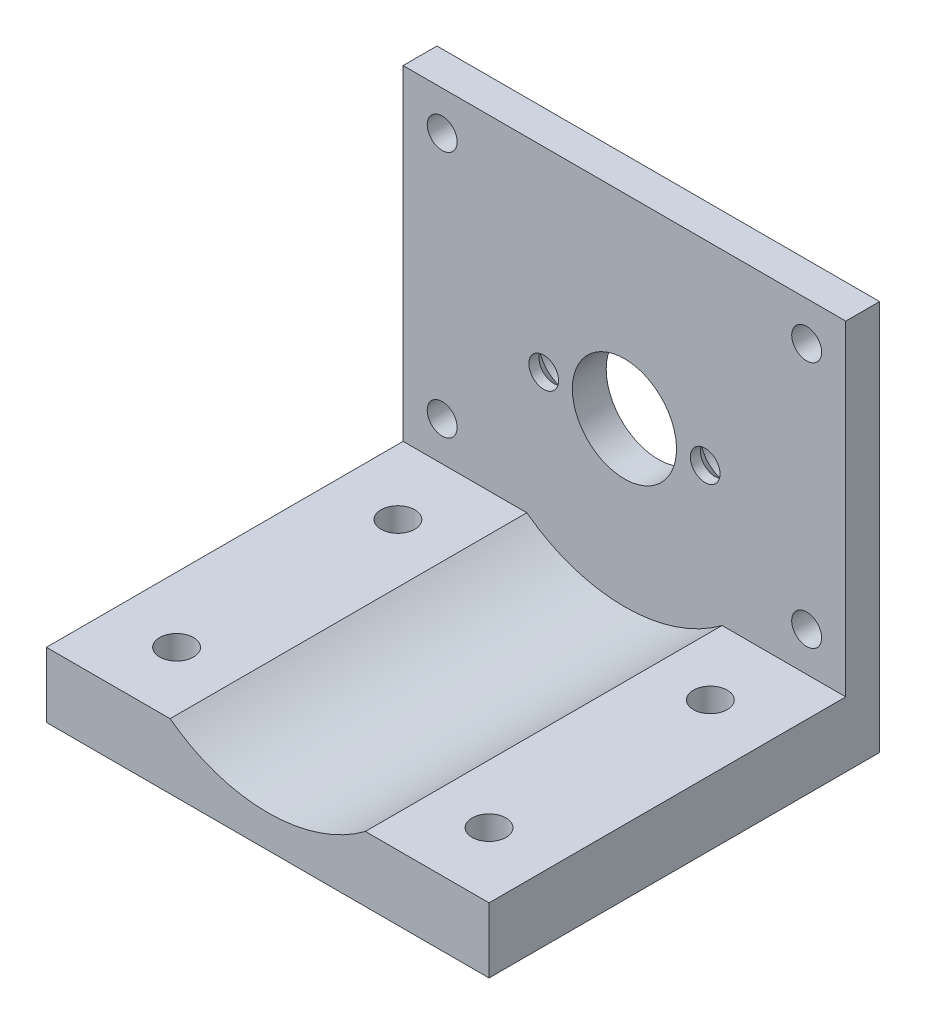
from build123d import *

# Parameters (mm, degrees)
SKETCH2_W                                      = 43.18
SKETCH2_H                                      = 38.1
BOSS_EXTRUDE1_DEPTH                            = 3.302
SKETCH4_R                                      = 5.08
SKETCH4_R_2                                    = 1.4605
CUT_EXTRUDE1_DEPTH                             = 4.302
CSK_FOR_M2_5_OVAL_HEAD_MACHINE_SCREW1_AT_COUNT = 2
CSK_FOR_M2_5_OVAL_HEAD_MACHINE_SCREW1_AT_PITCH = 15.748
BOSS_EXTRUDE2_START                            = -3.302
BOSS_EXTRUDE2_DEPTH                            = 38.1
SKETCH9_R                                      = 1.651
CUT_EXTRUDE2_DEPTH                             = 7.35
SKETCH10_W                                     = 0.569871795
SKETCH10_H                                     = 2.320192308
CUT_EXTRUDE3_DEPTH                             = 1.27


with BuildPart() as part:
    # Sketch2 → Boss-Extrude1 (new body)
    with BuildSketch(Plane.XY):
        with Locations((21.59, 19.05)):
            Rectangle(SKETCH2_W, SKETCH2_H)
    extrude(amount=BOSS_EXTRUDE1_DEPTH)

    # Sketch4 → Cut-Extrude1 (cut, through all)
    with BuildSketch(Plane(origin=(0, 0, 0), x_dir=(-1, 0, 0), z_dir=(0, 0, -1))):
        with Locations((-21.59, 19.05)):
            Circle(SKETCH4_R)
        with Locations((-3.81, 34.29)):
            Circle(SKETCH4_R_2)
        with Locations((-3.81, 10.16)):
            Circle(SKETCH4_R_2)
        with Locations((-39.37, 10.16)):
            Circle(SKETCH4_R_2)
        with Locations((-39.37, 34.29)):
            Circle(SKETCH4_R_2)
    extrude(amount=-CUT_EXTRUDE1_DEPTH, mode=Mode.SUBTRACT)

    # Sketch7 → CSK for M2.5 Oval Head Machine Screw1 (revolve, cut)
    with BuildSketch(Plane(origin=(29.464, 19.05, 0), x_dir=(0, 1, 0), z_dir=(1, 0, 0))):
        Polygon((0, 0), (0, 3.302), (1.45, 3.302), (1.45, 2.316), (2.75, 1.016), (2.75, 0), align=None)
    csk_for_m2_5_oval_head_machine_screw1 = revolve(axis=Axis((29.464, 19.05, -6.35), (0, 0, 1)), mode=Mode.SUBTRACT)

    # CSK for M2.5 Oval Head Machine Screw1 at: CSK for M2.5 Oval Head Machine Screw1 ×2
    with Locations(*[(-i * CSK_FOR_M2_5_OVAL_HEAD_MACHINE_SCREW1_AT_PITCH, 0, 0) for i in range(1, CSK_FOR_M2_5_OVAL_HEAD_MACHINE_SCREW1_AT_COUNT)]):
        add(csk_for_m2_5_oval_head_machine_screw1, mode=Mode.SUBTRACT)

    # Sketch8 → Boss-Extrude2 (add)
    with BuildSketch(Plane.XY.offset(3.302).offset(BOSS_EXTRUDE2_START)):
        with BuildLine():
            Line((31.115, 6.35), (43.18, 6.35))
            Line((43.18, 6.35), (43.18, 0))
            Line((43.18, 0), (0, 0))
            Line((0, 0), (0, 6.35))
            Line((0, 6.35), (12.065, 6.35))
            ThreePointArc((12.065, 6.35), (21.59, 3.175), (31.115, 6.35))
        make_face()
    extrude(amount=BOSS_EXTRUDE2_DEPTH)

    # Sketch9 → Cut-Extrude2 (cut, through all)
    with BuildSketch(Plane(origin=(0, 6.35, 0), x_dir=(1, 0, 0), z_dir=(0, 1, 0))):
        with Locations((6.35, -31.75)):
            Circle(SKETCH9_R)
        with Locations((6.35, -10.16)):
            Circle(SKETCH9_R)
        with Locations((36.83, -10.16)):
            Circle(SKETCH9_R)
        with Locations((36.83, -31.75)):
            Circle(SKETCH9_R)
    extrude(amount=-CUT_EXTRUDE2_DEPTH, mode=Mode.SUBTRACT)

    # Sketch10 → Cut-Extrude3 (cut)
    with BuildSketch(Plane(origin=(0, 0, 0), x_dir=(-1, 0, 0), z_dir=(0, 0, -1))):
        with BuildLine():
            Line((-35.883720469, 29.845), (-35.313848674, 29.845))
            Line((-35.313848674, 29.845), (-35.313848674, 27.73723758))
            add(Edge.make_bspline(
                [(-35.313848674, 27.73723758), (-35.314057606, 27.69695254), (-35.314460177, 27.619331222), (-35.318490626, 27.507585177), (-35.323940504, 27.405130731), (-35.331788854, 27.312132049), (-35.343445802, 27.228593628), (-35.356637927, 27.154307047), (-35.371192504, 27.08896961), (-35.395778755, 27.015846852), (-35.433948198, 26.934871717), (-35.491546976, 26.847407063), (-35.563275891, 26.771415182), (-35.645883908, 26.705407451), (-35.740067061, 26.653141814), (-35.843655591, 26.615364071), (-35.95631835, 26.592795386), (-36.034351478, 26.590019084), (-36.074525758, 26.588589744)],
                knots=[0, 0, 0, 0, 0.00012085, 0.000232854, 0.000335413, 0.000428639, 0.00051274, 0.000588343, 0.000654989, 0.000713315, 0.000819441, 0.000922634, 0.001026135, 0.001131624, 0.001238681, 0.001347739, 0.001461247, 0.001581696, 0.001581696, 0.001581696, 0.001581696], degree=3))
            add(Edge.make_bspline(
                [(-36.074525758, 26.588589744), (-36.116383701, 26.589885617), (-36.198943911, 26.592441587), (-36.320026962, 26.61421188), (-36.436402909, 26.64911621), (-36.547469686, 26.699583683), (-36.654748941, 26.762801011), (-36.756293653, 26.841215953), (-36.854223938, 26.932396519), (-36.912277608, 27.002366196), (-36.942053803, 27.038254207)],
                knots=[0, 0, 0, 0, 0.000125491, 0.000247517, 0.000367833, 0.000489111, 0.000612587, 0.000740558, 0.00087329, 0.001013058, 0.001013058, 0.001013058, 0.001013058], degree=3))
            Line((-36.942053803, 27.038254207), (-36.510833851, 27.43703726))
            add(Edge.make_bspline(
                [(-36.510833851, 27.43703726), (-36.488255661, 27.411507703), (-36.446005797, 27.363735039), (-36.382336499, 27.301438312), (-36.324903361, 27.251390082), (-36.270762922, 27.215289844), (-36.219671889, 27.189843205), (-36.170531002, 27.171513276), (-36.121808469, 27.161137495), (-36.089620879, 27.159340023), (-36.07388974, 27.158461538)],
                knots=[0, 0, 0, 0, 0.000102209, 0.000191261, 0.000267078, 0.000330405, 0.00038587, 0.000437981, 0.000487378, 0.000534598, 0.000534598, 0.000534598, 0.000534598], degree=3))
            add(Edge.make_bspline(
                [(-36.07388974, 27.158461538), (-36.058663749, 27.159255549), (-36.029389174, 27.160782171), (-35.98913551, 27.177752509), (-35.955199081, 27.204396654), (-35.932857339, 27.235027555), (-35.918619737, 27.266340582), (-35.909723815, 27.296609437), (-35.901281569, 27.33289359), (-35.89451783, 27.375174856), (-35.889407137, 27.424004736), (-35.886859826, 27.478790439), (-35.883761969, 27.539828017), (-35.883734794, 27.582468063), (-35.883720469, 27.604945913)],
                knots=[0, 0, 0, 0, 4.5443e-05, 8.7372e-05, 0.000128596, 0.000173627, 0.000199525, 0.00023151, 0.000268074, 0.000311257, 0.000359862, 0.000415287, 0.000475762, 0.000543183, 0.000543183, 0.000543183, 0.000543183], degree=3))
            Line((-35.883720469, 27.604945913), (-35.883720469, 29.845))
        make_face()
        with BuildLine():
            Line((-32.91224611, 28.990192308), (-32.342374315, 28.990192308))
            Line((-32.342374315, 28.990192308), (-32.342374315, 26.67))
            Line((-32.342374315, 26.67), (-32.91224611, 26.67))
            Line((-32.91224611, 26.67), (-32.91224611, 26.923135016))
            add(Edge.make_bspline(
                [(-32.91224611, 26.923135016), (-32.940483048, 26.898495124), (-32.995285367, 26.850673959), (-33.08163609, 26.788624782), (-33.168239139, 26.73744223), (-33.255510645, 26.696678118), (-33.344791934, 26.666578018), (-33.436725796, 26.644784842), (-33.532636176, 26.631932873), (-33.597834731, 26.630183365), (-33.63094603, 26.629294872)],
                knots=[0, 0, 0, 0, 0.000112381, 0.000218109, 0.000318463, 0.000413791, 0.000506513, 0.000600617, 0.000696864, 0.000796183, 0.000796183, 0.000796183, 0.000796183], degree=3))
            add(Edge.make_bspline(
                [(-33.63094603, 26.629294872), (-33.668114935, 26.630131056), (-33.741562798, 26.631783403), (-33.849339383, 26.649177023), (-33.95340839, 26.675801836), (-34.053685345, 26.713479273), (-34.149987803, 26.762301846), (-34.243052769, 26.820995704), (-34.331284827, 26.891621354), (-34.415418478, 26.971123004), (-34.492450744, 27.058575384), (-34.559793079, 27.152764668), (-34.616557662, 27.252354988), (-34.663061847, 27.357016157), (-34.699643394, 27.466671359), (-34.725720803, 27.581668388), (-34.741106504, 27.702048314), (-34.74301082, 27.784046405), (-34.743976879, 27.82564403)],
                knots=[0, 0, 0, 0, 0.000111419, 0.000220171, 0.000326612, 0.000433285, 0.000540802, 0.000650021, 0.000762762, 0.000879285, 0.000996914, 0.00111181, 0.00122604, 0.001340213, 0.001454856, 0.001572271, 0.001693444, 0.001818207, 0.001818207, 0.001818207, 0.001818207], degree=3))
            add(Edge.make_bspline(
                [(-34.743976879, 27.82564403), (-34.742962996, 27.868718426), (-34.740974152, 27.953213653), (-34.726425873, 28.077206381), (-34.70082969, 28.195054751), (-34.665927456, 28.306922001), (-34.621031792, 28.412827458), (-34.566351873, 28.512944627), (-34.50114383, 28.607011819), (-34.42600312, 28.693427944), (-34.344869608, 28.772632497), (-34.258071094, 28.841586342), (-34.166964917, 28.900165841), (-34.071454259, 28.947989445), (-33.971552761, 28.984945106), (-33.867654831, 29.011962712), (-33.759299237, 29.028174224), (-33.685486529, 29.02998216), (-33.648118506, 29.030897436)],
                knots=[0, 0, 0, 0, 0.000129212, 0.000253463, 0.000373846, 0.000490516, 0.000604512, 0.000718367, 0.000832164, 0.000947164, 0.00106141, 0.001171865, 0.001279133, 0.001385797, 0.001491651, 0.001598092, 0.001707378, 0.001819433, 0.001819433, 0.001819433, 0.001819433], degree=3))
            add(Edge.make_bspline(
                [(-33.648118506, 29.030897436), (-33.613503609, 29.030178304), (-33.545013205, 29.028755402), (-33.444342179, 29.013305404), (-33.346705804, 28.989938379), (-33.25263669, 28.956644575), (-33.161363253, 28.914604374), (-33.074455451, 28.861924869), (-32.9900121, 28.800820156), (-32.938488378, 28.75309608), (-32.91224611, 28.728789063)],
                knots=[0, 0, 0, 0, 0.000103766, 0.000205316, 0.000304814, 0.000404586, 0.000504179, 0.000605729, 0.000709024, 0.000816246, 0.000816246, 0.000816246, 0.000816246], degree=3))
            Line((-32.91224611, 28.728789063), (-32.91224611, 28.990192308))
        make_face()
        with BuildLine():
            add(Edge.make_bspline(
                [(-33.528547192, 28.501730769), (-33.551254903, 28.501034018), (-33.595760534, 28.499668432), (-33.661212156, 28.491454334), (-33.723764271, 28.476980729), (-33.782970763, 28.455599085), (-33.839714027, 28.429553127), (-33.893132408, 28.396930993), (-33.943666782, 28.358372324), (-33.991019952, 28.314810625), (-34.034189344, 28.266928353), (-34.07140388, 28.21467842), (-34.103030223, 28.159468665), (-34.129777889, 28.10113309), (-34.14892315, 28.038981407), (-34.164086188, 27.973822718), (-34.171954824, 27.905124712), (-34.173381159, 27.858309147), (-34.174105085, 27.834548277)],
                knots=[0, 0, 0, 0, 6.8128e-05, 0.000133527, 0.00019755, 0.000260313, 0.000322059, 0.000384561, 0.000447655, 0.000512472, 0.000577334, 0.000640697, 0.000704517, 0.000767998, 0.000832766, 0.000899269, 0.000968454, 0.001039759, 0.001039759, 0.001039759, 0.001039759], degree=3))
            add(Edge.make_bspline(
                [(-34.174105085, 27.834548277), (-34.173392217, 27.810571883), (-34.171987521, 27.763326676), (-34.16395896, 27.694049178), (-34.14934155, 27.627938674), (-34.128015301, 27.565529623), (-34.101971003, 27.505979922), (-34.070269236, 27.449564396), (-34.031329167, 27.397280544), (-33.988121932, 27.347891154), (-33.939797319, 27.303788346), (-33.888977001, 27.264629101), (-33.834966812, 27.231864586), (-33.778352726, 27.205384097), (-33.719325307, 27.183804725), (-33.657144532, 27.169513023), (-33.592419538, 27.160376608), (-33.5482948, 27.159104303), (-33.526003121, 27.158461538)],
                knots=[0, 0, 0, 0, 7.194e-05, 0.000141758, 0.000208881, 0.000274649, 0.000339292, 0.000403665, 0.000468289, 0.000534523, 0.00060024, 0.000664225, 0.000726727, 0.000789319, 0.000851483, 0.000914887, 0.000980369, 0.001047227, 0.001047227, 0.001047227, 0.001047227], degree=3))
            add(Edge.make_bspline(
                [(-33.526003121, 27.158461538), (-33.502872453, 27.159162196), (-33.457523767, 27.160535864), (-33.391004336, 27.168674999), (-33.327611922, 27.183201674), (-33.26761027, 27.204705733), (-33.210082914, 27.230564732), (-33.155548986, 27.262549405), (-33.104600261, 27.301019592), (-33.056978707, 27.34497509), (-33.013342733, 27.393248349), (-32.97561355, 27.446183457), (-32.942750052, 27.502087404), (-32.916904422, 27.562281961), (-32.896379367, 27.625714007), (-32.881653114, 27.692777213), (-32.873642886, 27.763543882), (-32.872250475, 27.811844891), (-32.871540982, 27.83645633)],
                knots=[0, 0, 0, 0, 6.9399e-05, 0.000136059, 0.000200702, 0.000264065, 0.000326966, 0.000389688, 0.000453289, 0.000518107, 0.000583866, 0.000648117, 0.000712806, 0.000778031, 0.000844205, 0.00091257, 0.000983651, 0.001057497, 0.001057497, 0.001057497, 0.001057497], degree=3))
            add(Edge.make_bspline(
                [(-32.871540982, 27.83645633), (-32.872241659, 27.860644464), (-32.873610285, 27.907890916), (-32.88168766, 27.977180011), (-32.896518462, 28.042926402), (-32.916621077, 28.10525094), (-32.942926508, 28.164011121), (-32.975814872, 28.218555434), (-33.013130188, 28.270773636), (-33.057249275, 28.317742768), (-33.104612852, 28.361379994), (-33.15631086, 28.398686815), (-33.210714533, 28.430838869), (-33.268158126, 28.457236944), (-33.329173542, 28.476587735), (-33.39267429, 28.491570343), (-33.459651113, 28.499663502), (-33.505207064, 28.501030435), (-33.528547192, 28.501730769)],
                knots=[0, 0, 0, 0, 7.2576e-05, 0.000141761, 0.000208885, 0.000274453, 0.000337934, 0.000401526, 0.000465261, 0.000530079, 0.000594468, 0.000658203, 0.000720924, 0.000783826, 0.000847383, 0.000912645, 0.000979306, 0.00104934, 0.00104934, 0.00104934, 0.00104934], degree=3))
        make_face(mode=Mode.SUBTRACT)
        with BuildLine():
            Line((-29.533720469, 28.516995192), (-30.005645549, 28.2575))
            add(Edge.make_bspline(
                [(-30.005645549, 28.2575), (-30.027276875, 28.279161867), (-30.068857721, 28.320801421), (-30.13553595, 28.37351049), (-30.201022726, 28.417152133), (-30.268017799, 28.449357424), (-30.337120025, 28.473611095), (-30.410821836, 28.489674834), (-30.489983464, 28.500252235), (-30.544739652, 28.501227763), (-30.572973274, 28.501730769)],
                knots=[0, 0, 0, 0, 9.1763e-05, 0.000176392, 0.000254542, 0.000327362, 0.000398769, 0.000473757, 0.000553277, 0.000637927, 0.000637927, 0.000637927, 0.000637927], degree=3))
            add(Edge.make_bspline(
                [(-30.572973274, 28.501730769), (-30.598865453, 28.501105378), (-30.649534278, 28.499881538), (-30.72356947, 28.4907403), (-30.793932334, 28.476382899), (-30.860496565, 28.455377972), (-30.923143604, 28.42762932), (-30.982391515, 28.394792964), (-31.037664566, 28.355586361), (-31.088181455, 28.310566822), (-31.133781827, 28.261001308), (-31.174459686, 28.208137557), (-31.207784458, 28.151191348), (-31.23659579, 28.091501123), (-31.257778233, 28.027945767), (-31.273275824, 27.961101977), (-31.282109306, 27.890966794), (-31.283389122, 27.843052482), (-31.284040982, 27.818647837)],
                knots=[0, 0, 0, 0, 7.7659e-05, 0.000151973, 0.000223448, 0.000292844, 0.000360909, 0.000428677, 0.000495737, 0.000563767, 0.000631281, 0.000697555, 0.000763438, 0.000828873, 0.000896051, 0.000963935, 0.001034461, 0.001107672, 0.001107672, 0.001107672, 0.001107672], degree=3))
            add(Edge.make_bspline(
                [(-31.284040982, 27.818647837), (-31.283352235, 27.794880072), (-31.282007409, 27.748471829), (-31.273745246, 27.68028706), (-31.259401822, 27.61537807), (-31.237895734, 27.554088013), (-31.212118283, 27.495851883), (-31.179746524, 27.441132841), (-31.141679119, 27.389691945), (-31.097715658, 27.341976291), (-31.0490153, 27.299061914), (-30.996512496, 27.261164076), (-30.940363891, 27.229033721), (-30.879915412, 27.203818613), (-30.816152609, 27.183273576), (-30.748649673, 27.168644704), (-30.677478437, 27.160524669), (-30.628962808, 27.159159879), (-30.604138137, 27.158461538)],
                knots=[0, 0, 0, 0, 7.1305e-05, 0.000139228, 0.000205731, 0.000270295, 0.000333776, 0.000396497, 0.000460609, 0.000525426, 0.000590763, 0.000655013, 0.000719386, 0.00078436, 0.000851139, 0.000920125, 0.000991206, 0.001065688, 0.001065688, 0.001065688, 0.001065688], degree=3))
            add(Edge.make_bspline(
                [(-30.604138137, 27.158461538), (-30.573573018, 27.159160958), (-30.513914347, 27.160526123), (-30.427187952, 27.172105012), (-30.345579602, 27.191252424), (-30.26908064, 27.217753962), (-30.197798092, 27.252405217), (-30.131915113, 27.29472914), (-30.070754426, 27.344413514), (-30.035088883, 27.38314857), (-30.017093867, 27.402692308)],
                knots=[0, 0, 0, 0, 9.1666e-05, 0.000178919, 0.000261916, 0.000342778, 0.000421287, 0.000499092, 0.00057727, 0.000656884, 0.000656884, 0.000656884, 0.000656884], degree=3))
            Line((-30.017093867, 27.402692308), (-29.574425597, 27.098675881))
            add(Edge.make_bspline(
                [(-29.574425597, 27.098675881), (-29.605109236, 27.061161254), (-29.665661062, 26.987128988), (-29.771307209, 26.891704101), (-29.885014373, 26.809712919), (-30.00906945, 26.744268597), (-30.141665788, 26.692216005), (-30.283839501, 26.65541999), (-30.435350111, 26.633759744), (-30.539404933, 26.630806952), (-30.59268982, 26.629294872)],
                knots=[0, 0, 0, 0, 0.000145216, 0.000286572, 0.000425645, 0.000564783, 0.000706159, 0.000852094, 0.001004374, 0.001164196, 0.001164196, 0.001164196, 0.001164196], degree=3))
            add(Edge.make_bspline(
                [(-30.59268982, 26.629294872), (-30.640649523, 26.630403558), (-30.734320112, 26.632568944), (-30.870842668, 26.649151716), (-30.999249221, 26.677083137), (-31.119803923, 26.715874142), (-31.232396863, 26.766123017), (-31.336662892, 26.828450398), (-31.433305283, 26.901122564), (-31.520580219, 26.984482815), (-31.598449487, 27.075221348), (-31.666429639, 27.17078345), (-31.725221983, 27.269456927), (-31.771344521, 27.372884161), (-31.809039345, 27.479453062), (-31.834497246, 27.59043751), (-31.8512883, 27.704923312), (-31.85303091, 27.782546076), (-31.853912777, 27.821827925)],
                knots=[0, 0, 0, 0, 0.000143854, 0.000280963, 0.000411829, 0.000537537, 0.000660236, 0.000780875, 0.00090121, 0.001022229, 0.001142196, 0.001259383, 0.0013737, 0.001486133, 0.001598572, 0.00171227, 0.001827222, 0.001944995, 0.001944995, 0.001944995, 0.001944995], degree=3))
            add(Edge.make_bspline(
                [(-31.853912777, 27.821827925), (-31.853440354, 27.849195922), (-31.852504631, 27.903403508), (-31.844516511, 27.98390782), (-31.832089681, 28.063046005), (-31.813413622, 28.140262556), (-31.790445366, 28.215932099), (-31.762524341, 28.290039423), (-31.728549239, 28.362202122), (-31.690649909, 28.433034055), (-31.647455228, 28.500665364), (-31.600330727, 28.5650662), (-31.549342801, 28.625842136), (-31.493892469, 28.682426759), (-31.434366367, 28.735224953), (-31.371629851, 28.785307896), (-31.303652796, 28.830092695), (-31.232798349, 28.872198679), (-31.15845617, 28.909681114), (-31.081480722, 28.942033398), (-31.002466853, 28.969521328), (-30.921225171, 28.991622179), (-30.838104381, 29.009837332), (-30.752364856, 29.021397417), (-30.664715945, 29.029522752), (-30.605429468, 29.030436445), (-30.575517344, 29.030897436)],
                knots=[0, 0, 0, 0, 8.2086e-05, 0.000162587, 0.000242472, 0.000322228, 0.000400693, 0.0004796, 0.000559559, 0.000639811, 0.000720445, 0.000800079, 0.000879071, 0.000958229, 0.00103751, 0.001117671, 0.001198815, 0.001281497, 0.001364837, 0.001448352, 0.001531825, 0.001615611, 0.001700811, 0.00178689, 0.001874991, 0.001964706, 0.001964706, 0.001964706, 0.001964706], degree=3))
            add(Edge.make_bspline(
                [(-30.575517344, 29.030897436), (-30.547732819, 29.030583308), (-30.49293586, 29.029963782), (-30.412013137, 29.023485774), (-30.333297823, 29.012482593), (-30.256655957, 28.997925848), (-30.181854779, 28.979887505), (-30.109896824, 28.955842999), (-30.039798304, 28.92855339), (-29.949510671, 28.88734893), (-29.843078076, 28.825844605), (-29.726243603, 28.737633843), (-29.622071525, 28.634440118), (-29.563327353, 28.556351578), (-29.533720469, 28.516995192)],
                knots=[0, 0, 0, 0, 8.334e-05, 0.000164364, 0.000243338, 0.000321674, 0.00039834, 0.000473965, 0.000549082, 0.000623933, 0.000771534, 0.000916802, 0.001062067, 0.001209672, 0.001209672, 0.001209672, 0.001209672], degree=3))
        make_face()
        Polygon((-28.963848674, 29.926410256), (-28.393976879, 29.926410256), (-28.393976879, 28.027261619), (-27.507368306, 28.990192308), (-26.803296791, 28.990192308), (-27.821561014, 27.884157652), (-26.657648754, 26.67), (-27.375076639, 26.67), (-28.393976879, 27.732785457), (-28.393976879, 26.67), (-28.963848674, 26.67), align=None)
        with BuildLine():
            Line((-22.187080846, 29.340002003), (-22.618300798, 28.927226563))
            add(Edge.make_bspline(
                [(-22.618300798, 28.927226563), (-22.652441234, 28.961407905), (-22.719430406, 29.028477342), (-22.828982816, 29.115772823), (-22.942445866, 29.189991239), (-23.060193006, 29.251018813), (-23.182388259, 29.298357105), (-23.308790483, 29.3322197), (-23.439605317, 29.352304178), (-23.52816112, 29.355115937), (-23.572963258, 29.356538462)],
                knots=[0, 0, 0, 0, 0.000144839, 0.000284198, 0.000419327, 0.000551032, 0.00068131, 0.000811675, 0.000942912, 0.001077294, 0.001077294, 0.001077294, 0.001077294], degree=3))
            add(Edge.make_bspline(
                [(-23.572963258, 29.356538462), (-23.611805341, 29.355541705), (-23.688075177, 29.353584486), (-23.800146355, 29.338721502), (-23.907237231, 29.313893554), (-24.009853746, 29.279498578), (-24.107369391, 29.234739844), (-24.200349189, 29.18030815), (-24.288220942, 29.115787088), (-24.370292724, 29.042399755), (-24.445019345, 28.962275604), (-24.510259631, 28.87651443), (-24.565830339, 28.786714749), (-24.611576365, 28.692417132), (-24.646384116, 28.593766307), (-24.671232296, 28.49083389), (-24.687004711, 28.383919017), (-24.688866962, 28.310980583), (-24.689810213, 28.274036458)],
                knots=[0, 0, 0, 0, 0.000116502, 0.000228763, 0.000338455, 0.000445857, 0.000552869, 0.000659769, 0.000768536, 0.000879349, 0.000989608, 0.001096716, 0.001202091, 0.00130592, 0.001410525, 0.001515267, 0.001623203, 0.001733987, 0.001733987, 0.001733987, 0.001733987], degree=3))
            add(Edge.make_bspline(
                [(-24.689810213, 28.274036458), (-24.688930394, 28.235813648), (-24.687197029, 28.160509478), (-24.670546105, 28.049997372), (-24.644892491, 27.943676762), (-24.607342439, 27.842336523), (-24.561129697, 27.744588436), (-24.502524326, 27.652325972), (-24.434184599, 27.564140184), (-24.356232629, 27.481566437), (-24.271441017, 27.405453315), (-24.179608942, 27.339796177), (-24.083530499, 27.283148239), (-23.981654978, 27.238284903), (-23.875750636, 27.202264559), (-23.764743299, 27.176867125), (-23.648882928, 27.161285888), (-23.569832442, 27.15941236), (-23.529714059, 27.158461538)],
                knots=[0, 0, 0, 0, 0.000114596, 0.00022577, 0.000334522, 0.000442167, 0.000549413, 0.000658292, 0.000769355, 0.000883644, 0.000998524, 0.001110611, 0.001221769, 0.00133252, 0.001443945, 0.001556879, 0.001673636, 0.001793951, 0.001793951, 0.001793951, 0.001793951], degree=3))
            add(Edge.make_bspline(
                [(-23.529714059, 27.158461538), (-23.503618536, 27.158696994), (-23.452387219, 27.159159245), (-23.377239607, 27.166662884), (-23.305266244, 27.177390208), (-23.236188398, 27.191591911), (-23.170703569, 27.211689869), (-23.107905075, 27.235191957), (-23.04816086, 27.262929106), (-22.991794851, 27.2958583), (-22.937968158, 27.332767902), (-22.887184609, 27.375000335), (-22.838553402, 27.421603414), (-22.792642785, 27.473146461), (-22.750229809, 27.530090332), (-22.70995567, 27.591388607), (-22.672281501, 27.657649634), (-22.650020828, 27.704439815), (-22.638653362, 27.728333333)],
                knots=[0, 0, 0, 0, 7.8253e-05, 0.000153629, 0.000226308, 0.000296538, 0.000364951, 0.000431575, 0.000497586, 0.000562275, 0.000627199, 0.000693161, 0.000760185, 0.000829113, 0.000899965, 0.000972997, 0.001049045, 0.001128405, 0.001128405, 0.001128405, 0.001128405], degree=3))
            Line((-22.638653362, 27.728333333), (-23.550066623, 27.728333333))
            Line((-23.550066623, 27.728333333), (-23.550066623, 28.298205128))
            Line((-23.550066623, 28.298205128), (-21.967018746, 28.298205128))
            Line((-21.967018746, 28.298205128), (-21.962566623, 28.162733373))
            add(Edge.make_bspline(
                [(-21.962566623, 28.162733373), (-21.963138688, 28.127940789), (-21.964281796, 28.058417712), (-21.97472861, 27.954909693), (-21.992033597, 27.852774494), (-22.01569117, 27.752114696), (-22.045340095, 27.652436526), (-22.083151754, 27.554694487), (-22.127428977, 27.458225725), (-22.177038463, 27.363440156), (-22.232785252, 27.272490826), (-22.292804855, 27.186373816), (-22.356241654, 27.105238176), (-22.42447537, 27.03021433), (-22.496443495, 26.960672044), (-22.572287696, 26.896878855), (-22.652276233, 26.838780786), (-22.735985372, 26.785887042), (-22.823891919, 26.739528796), (-22.915512563, 26.699203272), (-23.01070897, 26.664955656), (-23.109726915, 26.636880061), (-23.212371555, 26.615217506), (-23.318645088, 26.600363463), (-23.428605882, 26.590269974), (-23.503189963, 26.589156592), (-23.541162376, 26.588589744)],
                knots=[0, 0, 0, 0, 0.000104355, 0.000208524, 0.000311726, 0.000414935, 0.00051856, 0.000623448, 0.000729039, 0.000836864, 0.000944198, 0.001048825, 0.001151634, 0.001252944, 0.001352801, 0.001451662, 0.001550001, 0.001649173, 0.001748467, 0.001847853, 0.001949249, 0.002051727, 0.002156384, 0.00226369, 0.002373501, 0.002487392, 0.002487392, 0.002487392, 0.002487392], degree=3))
            add(Edge.make_bspline(
                [(-23.541162376, 26.588589744), (-23.581676367, 26.589149516), (-23.66198718, 26.590259153), (-23.78073748, 26.600651657), (-23.89604276, 26.617803815), (-24.00793178, 26.641541814), (-24.116664324, 26.671085651), (-24.222053571, 26.708170155), (-24.323883974, 26.752283344), (-24.422460465, 26.802257086), (-24.516523131, 26.858931662), (-24.605861161, 26.921313277), (-24.689986931, 26.989803203), (-24.769762151, 27.063254905), (-24.843322963, 27.143473831), (-24.913410691, 27.227859699), (-24.976629823, 27.319507443), (-25.035698596, 27.415445818), (-25.088175766, 27.515634621), (-25.134067806, 27.618220808), (-25.173204511, 27.722610404), (-25.204064749, 27.829289482), (-25.229120373, 27.937514186), (-25.247048141, 28.047755162), (-25.25717279, 28.159998608), (-25.258841889, 28.235432018), (-25.259682008, 28.273400441)],
                knots=[0, 0, 0, 0, 0.000121521, 0.000240891, 0.000357284, 0.000471047, 0.00058384, 0.000695077, 0.0008059, 0.000916548, 0.001026388, 0.001135078, 0.001243151, 0.001351612, 0.001460073, 0.001569442, 0.001680425, 0.001793759, 0.001907272, 0.002019444, 0.002130732, 0.002241425, 0.002352357, 0.00246382, 0.00257622, 0.002690131, 0.002690131, 0.002690131, 0.002690131], degree=3))
            add(Edge.make_bspline(
                [(-25.259682008, 28.273400441), (-25.258556909, 28.325197483), (-25.256335172, 28.427481286), (-25.235758519, 28.578145976), (-25.203682581, 28.72389903), (-25.157650382, 28.864209626), (-25.0985802, 28.999271043), (-25.027308818, 29.129400345), (-24.942288067, 29.254459214), (-24.876476166, 29.331888023), (-24.843090461, 29.371166867)],
                knots=[0, 0, 0, 0, 0.000155319, 0.000306708, 0.000455304, 0.00060253, 0.000748932, 0.000896948, 0.001047072, 0.001201639, 0.001201639, 0.001201639, 0.001201639], degree=3))
            add(Edge.make_bspline(
                [(-24.843090461, 29.371166867), (-24.822361603, 29.393890869), (-24.781215132, 29.43899767), (-24.715442572, 29.501674489), (-24.648002002, 29.560593018), (-24.577959358, 29.614503925), (-24.505682843, 29.664587348), (-24.430964431, 29.709904431), (-24.354196078, 29.751898096), (-24.274779084, 29.788423986), (-24.193129207, 29.821172494), (-24.108884834, 29.848882336), (-24.022676937, 29.87342667), (-23.933742143, 29.892098613), (-23.842978905, 29.907647182), (-23.749742955, 29.918068647), (-23.654288367, 29.925706839), (-23.589727685, 29.926173929), (-23.557062817, 29.926410256)],
                knots=[0, 0, 0, 0, 9.2249e-05, 0.000183113, 0.000272382, 0.000360798, 0.000448127, 0.000536045, 0.000622844, 0.000710488, 0.000798122, 0.000886618, 0.000976429, 0.001066871, 0.001159094, 0.00125258, 0.001348238, 0.001446204, 0.001446204, 0.001446204, 0.001446204], degree=3))
            add(Edge.make_bspline(
                [(-23.557062817, 29.926410256), (-23.522917425, 29.925883676), (-23.454980632, 29.924835974), (-23.353969872, 29.917586558), (-23.254362725, 29.906402419), (-23.156578943, 29.889625571), (-23.060290366, 29.868936226), (-22.965995404, 29.842428055), (-22.873078902, 29.812309997), (-22.81259061, 29.788297656), (-22.782393346, 29.776310096)],
                knots=[0, 0, 0, 0, 0.00010243, 0.000203799, 0.000303676, 0.000403009, 0.000501314, 0.00059899, 0.000696738, 0.000794184, 0.000794184, 0.000794184, 0.000794184], degree=3))
            add(Edge.make_bspline(
                [(-22.782393346, 29.776310096), (-22.756986083, 29.765231433), (-22.705308414, 29.742697739), (-22.630123775, 29.701471289), (-22.554755438, 29.655767038), (-22.480016668, 29.603913932), (-22.406021345, 29.54600896), (-22.331996879, 29.482966722), (-22.258698938, 29.414052109), (-22.211262712, 29.365005039), (-22.187080846, 29.340002003)],
                knots=[0, 0, 0, 0, 8.3114e-05, 0.000169052, 0.00025697, 0.000347477, 0.000441749, 0.000538743, 0.000639083, 0.000743425, 0.000743425, 0.000743425, 0.000743425], degree=3))
        make_face()
        with BuildLine():
            add(Edge.make_bspline(
                [(-20.368706447, 29.030897436), (-20.341764008, 29.030417977), (-20.288405772, 29.02946843), (-20.208935346, 29.021564324), (-20.130854245, 29.00866845), (-20.053713671, 28.991970543), (-19.978229946, 28.968574278), (-19.904007166, 28.940514075), (-19.830381687, 28.908297682), (-19.759180877, 28.869948905), (-19.689890364, 28.828356158), (-19.624198835, 28.782475947), (-19.56265181, 28.732668643), (-19.50410677, 28.680089069), (-19.451292006, 28.622448081), (-19.400832373, 28.562523064), (-19.35545408, 28.498167113), (-19.313440318, 28.430948435), (-19.276035768, 28.361255742), (-19.243556796, 28.28957384), (-19.215368101, 28.216893784), (-19.193296918, 28.14233028), (-19.175024013, 28.066866546), (-19.163492511, 27.989577832), (-19.155294413, 27.911258087), (-19.154375146, 27.858526789), (-19.153912777, 27.832004207)],
                knots=[0, 0, 0, 0, 8.0814e-05, 0.000160049, 0.000239307, 0.000318157, 0.000396622, 0.000476125, 0.000556137, 0.00063751, 0.000718554, 0.000798482, 0.000877648, 0.000955984, 0.001034284, 0.001111972, 0.001190861, 0.001270279, 0.00134967, 0.001427941, 0.001506254, 0.001583317, 0.00166107, 0.001738971, 0.001817573, 0.001897116, 0.001897116, 0.001897116, 0.001897116], degree=3))
            add(Edge.make_bspline(
                [(-19.153912777, 27.832004207), (-19.154400731, 27.805274416), (-19.155370894, 27.752129534), (-19.163195914, 27.673073095), (-19.17614115, 27.595420928), (-19.192903144, 27.518715572), (-19.216211854, 27.443938544), (-19.243445593, 27.369987602), (-19.276876079, 27.297870725), (-19.313835945, 27.226801186), (-19.356119838, 27.158870345), (-19.40145885, 27.093869703), (-19.451707134, 27.033504533), (-19.504099101, 26.975902744), (-19.56111982, 26.92301217), (-19.621859135, 26.873974009), (-19.685791212, 26.828188747), (-19.753375789, 26.786730594), (-19.823747222, 26.750302794), (-19.895718708, 26.717460159), (-19.969711098, 26.69011632), (-20.04557126, 26.667818172), (-20.123345201, 26.650553275), (-20.202861216, 26.638825025), (-20.283948057, 26.630668162), (-20.338581177, 26.629755582), (-20.366162376, 26.629294872)],
                knots=[0, 0, 0, 0, 8.0179e-05, 0.000159413, 0.000238043, 0.000316273, 0.000394738, 0.000472826, 0.000552519, 0.000633032, 0.000712991, 0.000792399, 0.000870578, 0.000948445, 0.001025846, 0.001103622, 0.001182512, 0.001261596, 0.00134125, 0.001420101, 0.001498785, 0.001577677, 0.001657148, 0.001737564, 0.001818698, 0.001901419, 0.001901419, 0.001901419, 0.001901419], degree=3))
            add(Edge.make_bspline(
                [(-20.366162376, 26.629294872), (-20.406491713, 26.630478617), (-20.485981451, 26.632811798), (-20.603051041, 26.648793474), (-20.715516272, 26.676302129), (-20.823560405, 26.714648588), (-20.92732379, 26.763788146), (-21.025900865, 26.824605811), (-21.120272203, 26.895904257), (-21.208803221, 26.977080864), (-21.289909627, 27.066138954), (-21.36076583, 27.161207921), (-21.420928481, 27.260862843), (-21.470343451, 27.365217359), (-21.508481731, 27.474414568), (-21.536024077, 27.588128009), (-21.552025292, 27.706677312), (-21.55433874, 27.787223129), (-21.555515341, 27.828188101)],
                knots=[0, 0, 0, 0, 0.000120979, 0.000238451, 0.000353683, 0.000467743, 0.000581824, 0.00069745, 0.000814605, 0.000936153, 0.001057272, 0.001175445, 0.001291284, 0.00140594, 0.0015212, 0.001637667, 0.0017564, 0.001879285, 0.001879285, 0.001879285, 0.001879285], degree=3))
            add(Edge.make_bspline(
                [(-21.555515341, 27.828188101), (-21.554297708, 27.871929711), (-21.551904475, 27.95790297), (-21.532901152, 28.083855753), (-21.502554896, 28.204449574), (-21.458994756, 28.319347093), (-21.403350509, 28.428760224), (-21.335421493, 28.532458201), (-21.254872, 28.630464515), (-21.193187218, 28.689742093), (-21.161820429, 28.719884816)],
                knots=[0, 0, 0, 0, 0.000131174, 0.00025782, 0.000381227, 0.000503607, 0.000625633, 0.000748764, 0.000874826, 0.001005248, 0.001005248, 0.001005248, 0.001005248], degree=3))
            add(Edge.make_bspline(
                [(-21.161820429, 28.719884816), (-21.133038265, 28.744869743), (-21.076257012, 28.794159831), (-20.984006165, 28.856676228), (-20.889551708, 28.910671322), (-20.791761562, 28.955065332), (-20.690363115, 28.988537699), (-20.585875976, 29.012902588), (-20.478321871, 29.027868216), (-20.405430606, 29.029882565), (-20.368706447, 29.030897436)],
                knots=[0, 0, 0, 0, 0.000114251, 0.000225395, 0.00033363, 0.000440378, 0.000546975, 0.000653426, 0.000761904, 0.000872053, 0.000872053, 0.000872053, 0.000872053], degree=3))
        make_face()
        with BuildLine():
            add(Edge.make_bspline(
                [(-20.355986094, 28.501730769), (-20.378049966, 28.500997439), (-20.421482936, 28.499553871), (-20.485417408, 28.491806627), (-20.545887306, 28.475927985), (-20.604093673, 28.455734697), (-20.659006833, 28.428729021), (-20.712130663, 28.397126156), (-20.76070284, 28.357579059), (-20.807073926, 28.314198787), (-20.849168537, 28.26602616), (-20.885037142, 28.213542118), (-20.917086536, 28.158754591), (-20.941387966, 28.09965774), (-20.961499722, 28.037866854), (-20.975111118, 27.972383578), (-20.984583698, 27.903939398), (-20.985286903, 27.857054665), (-20.985643546, 27.833276242)],
                knots=[0, 0, 0, 0, 6.6222e-05, 0.000130359, 0.000192679, 0.000253431, 0.000314875, 0.00037596, 0.000438438, 0.000502326, 0.000566346, 0.000629862, 0.000692815, 0.000756369, 0.000821136, 0.000887502, 0.000956767, 0.001028046, 0.001028046, 0.001028046, 0.001028046], degree=3))
            add(Edge.make_bspline(
                [(-20.985643546, 27.833276242), (-20.985226226, 27.808659272), (-20.984410653, 27.760550131), (-20.975965223, 27.690304316), (-20.962038432, 27.623641502), (-20.942252826, 27.560664671), (-20.917369086, 27.500921782), (-20.886839623, 27.444748032), (-20.850342232, 27.392481174), (-20.808963049, 27.344185569), (-20.763654611, 27.300347114), (-20.714009167, 27.262726592), (-20.66210568, 27.230039352), (-20.606748014, 27.203786453), (-20.548722405, 27.183517085), (-20.4878566, 27.168593431), (-20.423830749, 27.16055329), (-20.380175236, 27.159168377), (-20.357894147, 27.158461538)],
                knots=[0, 0, 0, 0, 7.3822e-05, 0.000144271, 0.00021188, 0.000277861, 0.000342001, 0.000405755, 0.000469271, 0.000532876, 0.000596303, 0.000658, 0.000719417, 0.000780013, 0.000841365, 0.000903532, 0.000967669, 0.001034526, 0.001034526, 0.001034526, 0.001034526], degree=3))
            add(Edge.make_bspline(
                [(-20.357894147, 27.158461538), (-20.335601914, 27.159088472), (-20.291896196, 27.160317625), (-20.227795158, 27.169522044), (-20.166618527, 27.184007984), (-20.108097335, 27.204451803), (-20.052704729, 27.231266632), (-20.000228663, 27.264110252), (-19.950207498, 27.302254041), (-19.904291016, 27.346919644), (-19.861787007, 27.395365866), (-19.824513534, 27.447908638), (-19.793366413, 27.504082401), (-19.767820197, 27.563533712), (-19.747995805, 27.626180853), (-19.734299575, 27.692256677), (-19.724821929, 27.761556409), (-19.724134628, 27.809074384), (-19.723784572, 27.833276242)],
                knots=[0, 0, 0, 0, 6.6858e-05, 0.00013108, 0.000193865, 0.000255217, 0.000316661, 0.000378079, 0.000440668, 0.000504993, 0.000569911, 0.000633792, 0.000697853, 0.000762242, 0.000827616, 0.000894603, 0.000964498, 0.001037049, 0.001037049, 0.001037049, 0.001037049], degree=3))
            add(Edge.make_bspline(
                [(-19.723784572, 27.833276242), (-19.724207201, 27.857469642), (-19.725036537, 27.90494494), (-19.733482568, 27.974338399), (-19.747272686, 28.040200647), (-19.767313482, 28.102250458), (-19.792049317, 28.161195721), (-19.822599882, 28.216734719), (-19.859277267, 28.268593906), (-19.900857605, 28.316516136), (-19.946845245, 28.359739438), (-19.995628725, 28.398284131), (-20.048323573, 28.430163553), (-20.103941201, 28.456443576), (-20.162629583, 28.476662303), (-20.22432283, 28.491670533), (-20.289210014, 28.499596267), (-20.333494771, 28.501011832), (-20.355986094, 28.501730769)],
                knots=[0, 0, 0, 0, 7.2551e-05, 0.000142368, 0.000209355, 0.000274123, 0.000337677, 0.000400874, 0.000463868, 0.000527889, 0.000590877, 0.000652963, 0.000714047, 0.000775217, 0.000837169, 0.000899955, 0.000965353, 0.001032846, 0.001032846, 0.001032846, 0.001032846], degree=3))
        make_face(mode=Mode.SUBTRACT)
        with BuildLine():
            add(Edge.make_bspline(
                [(-17.560052601, 29.030897436), (-17.533110162, 29.030417977), (-17.479751926, 29.02946843), (-17.400281499, 29.021564324), (-17.322200399, 29.00866845), (-17.245059825, 28.991970543), (-17.1695761, 28.968574278), (-17.09535332, 28.940514075), (-17.021727841, 28.908297682), (-16.950527031, 28.869948905), (-16.881236518, 28.828356158), (-16.815544988, 28.782475947), (-16.753997964, 28.732668643), (-16.695452924, 28.680089069), (-16.64263816, 28.622448081), (-16.592178527, 28.562523064), (-16.546800234, 28.498167113), (-16.504786472, 28.430948435), (-16.467381922, 28.361255742), (-16.43490295, 28.28957384), (-16.406714255, 28.216893784), (-16.384643072, 28.14233028), (-16.366370167, 28.066866546), (-16.354838665, 27.989577832), (-16.346640567, 27.911258087), (-16.3457213, 27.858526789), (-16.345258931, 27.832004207)],
                knots=[0, 0, 0, 0, 8.0814e-05, 0.000160049, 0.000239307, 0.000318157, 0.000396622, 0.000476125, 0.000556137, 0.00063751, 0.000718554, 0.000798482, 0.000877648, 0.000955984, 0.001034284, 0.001111972, 0.001190861, 0.001270279, 0.00134967, 0.001427941, 0.001506254, 0.001583317, 0.00166107, 0.001738971, 0.001817573, 0.001897116, 0.001897116, 0.001897116, 0.001897116], degree=3))
            add(Edge.make_bspline(
                [(-16.345258931, 27.832004207), (-16.345746885, 27.805274416), (-16.346717048, 27.752129534), (-16.354542068, 27.673073095), (-16.367487304, 27.595420928), (-16.384249298, 27.518715572), (-16.407558008, 27.443938544), (-16.434791747, 27.369987602), (-16.468222233, 27.297870725), (-16.505182099, 27.226801186), (-16.547465992, 27.158870345), (-16.592805004, 27.093869703), (-16.643053288, 27.033504533), (-16.695445255, 26.975902744), (-16.752465974, 26.92301217), (-16.813205289, 26.873974009), (-16.877137366, 26.828188747), (-16.944721943, 26.786730594), (-17.015093375, 26.750302794), (-17.087064862, 26.717460159), (-17.161057252, 26.69011632), (-17.236917414, 26.667818172), (-17.314691355, 26.650553275), (-17.39420737, 26.638825025), (-17.475294211, 26.630668162), (-17.529927331, 26.629755582), (-17.55750853, 26.629294872)],
                knots=[0, 0, 0, 0, 8.0179e-05, 0.000159413, 0.000238043, 0.000316273, 0.000394738, 0.000472826, 0.000552519, 0.000633032, 0.000712991, 0.000792399, 0.000870578, 0.000948445, 0.001025846, 0.001103622, 0.001182512, 0.001261596, 0.00134125, 0.001420101, 0.001498785, 0.001577677, 0.001657148, 0.001737564, 0.001818698, 0.001901419, 0.001901419, 0.001901419, 0.001901419], degree=3))
            add(Edge.make_bspline(
                [(-17.55750853, 26.629294872), (-17.597837867, 26.630478617), (-17.677327605, 26.632811798), (-17.794397195, 26.648793474), (-17.906862426, 26.676302129), (-18.014906558, 26.714648588), (-18.118669944, 26.763788146), (-18.217247019, 26.824605811), (-18.311618357, 26.895904257), (-18.400149375, 26.977080864), (-18.481255781, 27.066138954), (-18.552111984, 27.161207921), (-18.612274635, 27.260862843), (-18.661689605, 27.365217359), (-18.699827885, 27.474414568), (-18.727370231, 27.588128009), (-18.743371446, 27.706677312), (-18.745684894, 27.787223129), (-18.746861495, 27.828188101)],
                knots=[0, 0, 0, 0, 0.000120979, 0.000238451, 0.000353683, 0.000467743, 0.000581824, 0.00069745, 0.000814605, 0.000936153, 0.001057272, 0.001175445, 0.001291284, 0.00140594, 0.0015212, 0.001637667, 0.0017564, 0.001879285, 0.001879285, 0.001879285, 0.001879285], degree=3))
            add(Edge.make_bspline(
                [(-18.746861495, 27.828188101), (-18.745643862, 27.871929711), (-18.743250629, 27.95790297), (-18.724247306, 28.083855753), (-18.69390105, 28.204449574), (-18.65034091, 28.319347093), (-18.594696662, 28.428760224), (-18.526767647, 28.532458201), (-18.446218154, 28.630464515), (-18.384533372, 28.689742093), (-18.353166583, 28.719884816)],
                knots=[0, 0, 0, 0, 0.000131174, 0.00025782, 0.000381227, 0.000503607, 0.000625633, 0.000748764, 0.000874826, 0.001005248, 0.001005248, 0.001005248, 0.001005248], degree=3))
            add(Edge.make_bspline(
                [(-18.353166583, 28.719884816), (-18.324384418, 28.744869743), (-18.267603166, 28.794159831), (-18.175352319, 28.856676228), (-18.080897862, 28.910671322), (-17.983107716, 28.955065332), (-17.881709269, 28.988537699), (-17.77722213, 29.012902588), (-17.669668025, 29.027868216), (-17.59677676, 29.029882565), (-17.560052601, 29.030897436)],
                knots=[0, 0, 0, 0, 0.000114251, 0.000225395, 0.00033363, 0.000440378, 0.000546975, 0.000653426, 0.000761904, 0.000872053, 0.000872053, 0.000872053, 0.000872053], degree=3))
        make_face()
        with BuildLine():
            add(Edge.make_bspline(
                [(-17.547332248, 28.501730769), (-17.56939612, 28.500997439), (-17.61282909, 28.499553871), (-17.676763562, 28.491806627), (-17.737233459, 28.475927985), (-17.795439826, 28.455734697), (-17.850352987, 28.428729021), (-17.903476817, 28.397126156), (-17.952048993, 28.357579059), (-17.99842008, 28.314198787), (-18.040514691, 28.26602616), (-18.076383296, 28.213542118), (-18.10843269, 28.158754591), (-18.132734119, 28.09965774), (-18.152845876, 28.037866854), (-18.166457271, 27.972383578), (-18.175929852, 27.903939398), (-18.176633057, 27.857054665), (-18.1769897, 27.833276242)],
                knots=[0, 0, 0, 0, 6.6222e-05, 0.000130359, 0.000192679, 0.000253431, 0.000314875, 0.00037596, 0.000438438, 0.000502326, 0.000566346, 0.000629862, 0.000692815, 0.000756369, 0.000821136, 0.000887502, 0.000956767, 0.001028046, 0.001028046, 0.001028046, 0.001028046], degree=3))
            add(Edge.make_bspline(
                [(-18.1769897, 27.833276242), (-18.176572379, 27.808659272), (-18.175756806, 27.760550131), (-18.167311377, 27.690304316), (-18.153384586, 27.623641502), (-18.13359898, 27.560664671), (-18.10871524, 27.500921782), (-18.078185777, 27.444748032), (-18.041688386, 27.392481174), (-18.000309203, 27.344185569), (-17.955000765, 27.300347114), (-17.90535532, 27.262726592), (-17.853451834, 27.230039352), (-17.798094168, 27.203786453), (-17.740068559, 27.183517085), (-17.679202754, 27.168593431), (-17.615176902, 27.16055329), (-17.57152139, 27.159168377), (-17.549240301, 27.158461538)],
                knots=[0, 0, 0, 0, 7.3822e-05, 0.000144271, 0.00021188, 0.000277861, 0.000342001, 0.000405755, 0.000469271, 0.000532876, 0.000596303, 0.000658, 0.000719417, 0.000780013, 0.000841365, 0.000903532, 0.000967669, 0.001034526, 0.001034526, 0.001034526, 0.001034526], degree=3))
            add(Edge.make_bspline(
                [(-17.549240301, 27.158461538), (-17.526948068, 27.159088472), (-17.48324235, 27.160317625), (-17.419141312, 27.169522044), (-17.357964681, 27.184007984), (-17.299443488, 27.204451803), (-17.244050883, 27.231266632), (-17.191574817, 27.264110252), (-17.141553652, 27.302254041), (-17.09563717, 27.346919644), (-17.053133161, 27.395365866), (-17.015859687, 27.447908638), (-16.984712567, 27.504082401), (-16.959166351, 27.563533712), (-16.939341959, 27.626180853), (-16.925645728, 27.692256677), (-16.916168083, 27.761556409), (-16.915480782, 27.809074384), (-16.915130726, 27.833276242)],
                knots=[0, 0, 0, 0, 6.6858e-05, 0.00013108, 0.000193865, 0.000255217, 0.000316661, 0.000378079, 0.000440668, 0.000504993, 0.000569911, 0.000633792, 0.000697853, 0.000762242, 0.000827616, 0.000894603, 0.000964498, 0.001037049, 0.001037049, 0.001037049, 0.001037049], degree=3))
            add(Edge.make_bspline(
                [(-16.915130726, 27.833276242), (-16.915553355, 27.857469642), (-16.916382691, 27.90494494), (-16.924828722, 27.974338399), (-16.93861884, 28.040200647), (-16.958659636, 28.102250458), (-16.983395471, 28.161195721), (-17.013946036, 28.216734719), (-17.05062342, 28.268593906), (-17.092203759, 28.316516136), (-17.138191399, 28.359739438), (-17.186974879, 28.398284131), (-17.239669726, 28.430163553), (-17.295287355, 28.456443576), (-17.353975737, 28.476662303), (-17.415668984, 28.491670533), (-17.480556167, 28.499596267), (-17.524840924, 28.501011832), (-17.547332248, 28.501730769)],
                knots=[0, 0, 0, 0, 7.2551e-05, 0.000142368, 0.000209355, 0.000274123, 0.000337677, 0.000400874, 0.000463868, 0.000527889, 0.000590877, 0.000652963, 0.000714047, 0.000775217, 0.000837169, 0.000899955, 0.000965353, 0.001032846, 0.001032846, 0.001032846, 0.001032846], degree=3))
        make_face(mode=Mode.SUBTRACT)
        with BuildLine():
            Line((-14.106476879, 29.926410256), (-13.536605085, 29.926410256))
            Line((-13.536605085, 29.926410256), (-13.536605085, 26.67))
            Line((-13.536605085, 26.67), (-14.106476879, 26.67))
            Line((-14.106476879, 26.67), (-14.106476879, 26.923135016))
            add(Edge.make_bspline(
                [(-14.106476879, 26.923135016), (-14.134713817, 26.898495124), (-14.189516136, 26.850673959), (-14.275866859, 26.788624782), (-14.362469908, 26.73744223), (-14.449741414, 26.696678118), (-14.539022703, 26.666578018), (-14.630956565, 26.644784842), (-14.726866945, 26.631932873), (-14.7920655, 26.630183365), (-14.825176799, 26.629294872)],
                knots=[0, 0, 0, 0, 0.000112381, 0.000218109, 0.000318463, 0.000413791, 0.000506513, 0.000600617, 0.000696864, 0.000796183, 0.000796183, 0.000796183, 0.000796183], degree=3))
            add(Edge.make_bspline(
                [(-14.825176799, 26.629294872), (-14.862345704, 26.630131056), (-14.935793567, 26.631783403), (-15.043570152, 26.649177023), (-15.14763916, 26.675801836), (-15.247916115, 26.713479273), (-15.344218572, 26.762301846), (-15.437283539, 26.820995704), (-15.525515596, 26.891621354), (-15.609649247, 26.971123004), (-15.686681514, 27.058575384), (-15.754023848, 27.152764668), (-15.810788431, 27.252354988), (-15.857292616, 27.357016157), (-15.893874163, 27.466671359), (-15.919951572, 27.581668388), (-15.935337273, 27.702048314), (-15.937241589, 27.784046405), (-15.938207649, 27.82564403)],
                knots=[0, 0, 0, 0, 0.000111419, 0.000220171, 0.000326612, 0.000433285, 0.000540802, 0.000650021, 0.000762762, 0.000879285, 0.000996914, 0.00111181, 0.00122604, 0.001340213, 0.001454856, 0.001572271, 0.001693444, 0.001818207, 0.001818207, 0.001818207, 0.001818207], degree=3))
            add(Edge.make_bspline(
                [(-15.938207649, 27.82564403), (-15.937193766, 27.868718426), (-15.935204921, 27.953213653), (-15.920656642, 28.077206381), (-15.89506046, 28.195054751), (-15.860158225, 28.306922001), (-15.815262561, 28.412827458), (-15.760582642, 28.512944627), (-15.695374599, 28.607011819), (-15.620233889, 28.693427944), (-15.539100378, 28.772632497), (-15.452301864, 28.841586342), (-15.361195686, 28.900165841), (-15.265685028, 28.947989445), (-15.16578353, 28.984945106), (-15.0618856, 29.011962712), (-14.953530007, 29.028174224), (-14.879717298, 29.02998216), (-14.842349275, 29.030897436)],
                knots=[0, 0, 0, 0, 0.000129212, 0.000253463, 0.000373846, 0.000490516, 0.000604512, 0.000718367, 0.000832164, 0.000947164, 0.00106141, 0.001171865, 0.001279133, 0.001385797, 0.001491651, 0.001598092, 0.001707378, 0.001819433, 0.001819433, 0.001819433, 0.001819433], degree=3))
            add(Edge.make_bspline(
                [(-14.842349275, 29.030897436), (-14.807756694, 29.029799923), (-14.739349863, 29.027629591), (-14.638301191, 29.013967893), (-14.541073177, 28.988244108), (-14.446484991, 28.955100901), (-14.355765041, 28.91050145), (-14.26842593, 28.856926832), (-14.184237534, 28.793696663), (-14.132724782, 28.744799809), (-14.106476879, 28.719884816)],
                knots=[0, 0, 0, 0, 0.000103796, 0.000205256, 0.000305062, 0.000405046, 0.000505459, 0.000607668, 0.000712102, 0.000820601, 0.000820601, 0.000820601, 0.000820601], degree=3))
            Line((-14.106476879, 28.719884816), (-14.106476879, 29.926410256))
        make_face()
        with BuildLine():
            add(Edge.make_bspline(
                [(-14.722777961, 28.501730769), (-14.745485672, 28.501034018), (-14.789991304, 28.499668432), (-14.855442925, 28.491454334), (-14.91799504, 28.476980729), (-14.977201533, 28.455599085), (-15.033944797, 28.429553127), (-15.087363177, 28.396930993), (-15.137897551, 28.358372324), (-15.185250722, 28.314810625), (-15.228420114, 28.266928353), (-15.265634649, 28.21467842), (-15.297260992, 28.159468665), (-15.324008658, 28.10113309), (-15.343153919, 28.038981407), (-15.358316958, 27.973822718), (-15.366185593, 27.905124712), (-15.367611929, 27.858309147), (-15.368335854, 27.834548277)],
                knots=[0, 0, 0, 0, 6.8128e-05, 0.000133527, 0.00019755, 0.000260313, 0.000322059, 0.000384561, 0.000447655, 0.000512472, 0.000577334, 0.000640697, 0.000704517, 0.000767998, 0.000832766, 0.000899269, 0.000968454, 0.001039759, 0.001039759, 0.001039759, 0.001039759], degree=3))
            add(Edge.make_bspline(
                [(-15.368335854, 27.834548277), (-15.367622987, 27.810571883), (-15.36621829, 27.763326676), (-15.358189729, 27.694049178), (-15.34357232, 27.627938674), (-15.32224607, 27.565529623), (-15.296201772, 27.505979922), (-15.264500005, 27.449564396), (-15.225559936, 27.397280544), (-15.182352701, 27.347891154), (-15.134028088, 27.303788346), (-15.08320777, 27.264629101), (-15.029197581, 27.231864586), (-14.972583495, 27.205384097), (-14.913556076, 27.183804725), (-14.851375301, 27.169513023), (-14.786650307, 27.160376608), (-14.74252557, 27.159104303), (-14.720233891, 27.158461538)],
                knots=[0, 0, 0, 0, 7.194e-05, 0.000141758, 0.000208881, 0.000274649, 0.000339292, 0.000403665, 0.000468289, 0.000534523, 0.00060024, 0.000664225, 0.000726727, 0.000789319, 0.000851483, 0.000914887, 0.000980369, 0.001047227, 0.001047227, 0.001047227, 0.001047227], degree=3))
            add(Edge.make_bspline(
                [(-14.720233891, 27.158461538), (-14.697103222, 27.159162196), (-14.651754537, 27.160535864), (-14.585235105, 27.168674999), (-14.521842691, 27.183201674), (-14.46184104, 27.204705733), (-14.404313684, 27.230564732), (-14.349779755, 27.262549405), (-14.29883103, 27.301019592), (-14.251209477, 27.34497509), (-14.207573503, 27.393248349), (-14.16984432, 27.446183457), (-14.136980821, 27.502087404), (-14.111135191, 27.562281961), (-14.090610137, 27.625714007), (-14.075883884, 27.692777213), (-14.067873656, 27.763543882), (-14.066481245, 27.811844891), (-14.065771751, 27.83645633)],
                knots=[0, 0, 0, 0, 6.9399e-05, 0.000136059, 0.000200702, 0.000264065, 0.000326966, 0.000389688, 0.000453289, 0.000518107, 0.000583866, 0.000648117, 0.000712806, 0.000778031, 0.000844205, 0.00091257, 0.000983651, 0.001057497, 0.001057497, 0.001057497, 0.001057497], degree=3))
            add(Edge.make_bspline(
                [(-14.065771751, 27.83645633), (-14.066472428, 27.860644464), (-14.067841054, 27.907890916), (-14.07591843, 27.977180011), (-14.090749231, 28.042926402), (-14.110851846, 28.10525094), (-14.137157277, 28.164011121), (-14.170045641, 28.218555434), (-14.207360957, 28.270773636), (-14.251480044, 28.317742768), (-14.298843621, 28.361379994), (-14.35054163, 28.398686815), (-14.404945302, 28.430838869), (-14.462388895, 28.457236944), (-14.523404311, 28.476587735), (-14.586905059, 28.491570343), (-14.653881882, 28.499663502), (-14.699437833, 28.501030435), (-14.722777961, 28.501730769)],
                knots=[0, 0, 0, 0, 7.2576e-05, 0.000141761, 0.000208885, 0.000274453, 0.000337934, 0.000401526, 0.000465261, 0.000530079, 0.000594468, 0.000658203, 0.000720924, 0.000783826, 0.000847383, 0.000912645, 0.000979306, 0.00104934, 0.00104934, 0.00104934, 0.00104934], degree=3))
        make_face(mode=Mode.SUBTRACT)
        Polygon((-13.231316623, 28.990192308), (-12.662716863, 28.990192308), (-12.17298329, 27.670455729), (-11.654628923, 28.990192308), (-11.305455245, 28.990192308), (-10.789008931, 27.685084135), (-10.30118341, 28.990192308), (-9.730675597, 28.990192308), (-10.598203642, 26.67), (-10.957553602, 26.67), (-11.48099611, 27.992280649), (-12.000622512, 26.67), (-12.370784772, 26.67), align=None)
        with BuildLine():
            add(Edge.make_bspline(
                [(-9.22313353, 29.967115385), (-9.19857206, 29.965910306), (-9.150343246, 29.963544018), (-9.081248908, 29.940477972), (-9.017834309, 29.904276503), (-8.961774044, 29.854607225), (-8.915148358, 29.795293022), (-8.879524603, 29.728886828), (-8.859680092, 29.655310904), (-8.856923983, 29.604485425), (-8.855515341, 29.578508614)],
                knots=[0, 0, 0, 0, 7.3476e-05, 0.000144277, 0.000216065, 0.000291333, 0.000367422, 0.000441389, 0.000515914, 0.000593823, 0.000593823, 0.000593823, 0.000593823], degree=3))
            add(Edge.make_bspline(
                [(-8.855515341, 29.578508614), (-8.856873584, 29.552723237), (-8.859520187, 29.502479203), (-8.879981336, 29.429902107), (-8.914175278, 29.363528166), (-8.961178603, 29.305094889), (-9.016631101, 29.256225564), (-9.078660043, 29.219366879), (-9.147092257, 29.197583993), (-9.194572705, 29.195019896), (-9.218681407, 29.193717949)],
                knots=[0, 0, 0, 0, 7.7275e-05, 0.000150575, 0.000224249, 0.000299839, 0.000374209, 0.000444896, 0.000514898, 0.000587108, 0.000587108, 0.000587108, 0.000587108], degree=3))
            add(Edge.make_bspline(
                [(-9.218681407, 29.193717949), (-9.243457278, 29.194918719), (-9.29210568, 29.19727648), (-9.361766735, 29.220396495), (-9.426027123, 29.256312854), (-9.481844198, 29.306996953), (-9.529003852, 29.366732628), (-9.563071548, 29.434684816), (-9.584381735, 29.50876385), (-9.586911235, 29.560342089), (-9.588207649, 29.586776843)],
                knots=[0, 0, 0, 0, 7.4109e-05, 0.000145516, 0.000217857, 0.000293546, 0.000370135, 0.000444942, 0.000520251, 0.000599427, 0.000599427, 0.000599427, 0.000599427], degree=3))
            add(Edge.make_bspline(
                [(-9.588207649, 29.586776843), (-9.586796796, 29.612124368), (-9.584025381, 29.661915923), (-9.564062, 29.733856038), (-9.529255096, 29.79914584), (-9.482965259, 29.857374241), (-9.427397392, 29.906117001), (-9.364020862, 29.941219008), (-9.295391531, 29.96333236), (-9.24746823, 29.965841356), (-9.22313353, 29.967115385)],
                knots=[0, 0, 0, 0, 7.6009e-05, 0.000149308, 0.000221853, 0.000296549, 0.0003714, 0.000442009, 0.000512619, 0.000585461, 0.000585461, 0.000585461, 0.000585461], degree=3))
        make_face()
        with Locations((-9.221861495, 27.830096154)):
            Rectangle(SKETCH10_W, SKETCH10_H)
        with BuildLine():
            Line((-8.407758931, 28.990192308), (-7.837887136, 28.990192308))
            Line((-7.837887136, 28.990192308), (-7.837887136, 28.744689503))
            add(Edge.make_bspline(
                [(-7.837887136, 28.744689503), (-7.805376232, 28.769977153), (-7.743241576, 28.818306769), (-7.64878617, 28.879927275), (-7.559631962, 28.930361185), (-7.473791608, 28.968723797), (-7.38965002, 28.996324047), (-7.305844464, 29.016153181), (-7.221126907, 29.02885032), (-7.164176144, 29.03021543), (-7.135723674, 29.030897436)],
                knots=[0, 0, 0, 0, 0.000123515, 0.000236062, 0.000337991, 0.000430531, 0.000517619, 0.000603239, 0.000688688, 0.000774, 0.000774, 0.000774, 0.000774], degree=3))
            add(Edge.make_bspline(
                [(-7.135723674, 29.030897436), (-7.106862473, 29.030118044), (-7.05020551, 29.028588033), (-6.966781255, 29.017886845), (-6.887077481, 28.998396591), (-6.810197985, 28.972518806), (-6.736925268, 28.938361613), (-6.666361696, 28.897805489), (-6.600022948, 28.848405385), (-6.55916861, 28.810784638), (-6.538503121, 28.791754808)],
                knots=[0, 0, 0, 0, 8.6583e-05, 0.000169969, 0.000251729, 0.000332383, 0.000412919, 0.00049386, 0.000576163, 0.000660408, 0.000660408, 0.000660408, 0.000660408], degree=3))
            add(Edge.make_bspline(
                [(-6.538503121, 28.791754808), (-6.521928639, 28.77411972), (-6.488658368, 28.738720476), (-6.446791913, 28.678143303), (-6.410865785, 28.612103097), (-6.381429316, 28.539838062), (-6.35967695, 28.460951149), (-6.342942559, 28.376395199), (-6.3335526, 28.285696762), (-6.332393366, 28.223387791), (-6.331797392, 28.191354167)],
                knots=[0, 0, 0, 0, 7.252e-05, 0.000145571, 0.000220137, 0.000297734, 0.000379069, 0.000465261, 0.000556078, 0.000652169, 0.000652169, 0.000652169, 0.000652169], degree=3))
            Line((-6.331797392, 28.191354167), (-6.331797392, 26.67))
            Line((-6.331797392, 26.67), (-6.901669187, 26.67))
            Line((-6.901669187, 26.67), (-6.901669187, 27.677451923))
            add(Edge.make_bspline(
                [(-6.901669187, 27.677451923), (-6.901789702, 27.71031325), (-6.902020648, 27.773285883), (-6.903793796, 27.863409185), (-6.907256014, 27.94480223), (-6.910411736, 28.017613213), (-6.916607672, 28.081583603), (-6.922195267, 28.137118384), (-6.930768891, 28.183713739), (-6.941924565, 28.233834035), (-6.961405121, 28.287496978), (-6.991647735, 28.344039753), (-7.030014731, 28.392074101), (-7.074939048, 28.431936766), (-7.126371071, 28.463471791), (-7.183689319, 28.485658645), (-7.246586498, 28.499486038), (-7.290412513, 28.500963488), (-7.313172593, 28.501730769)],
                knots=[0, 0, 0, 0, 9.8585e-05, 0.000188919, 0.000270392, 0.000342998, 0.00040749, 0.000463188, 0.000510348, 0.000549534, 0.000617132, 0.000680886, 0.00074108, 0.000800553, 0.00086022, 0.000921046, 0.000984169, 0.001052368, 0.001052368, 0.001052368, 0.001052368], degree=3))
            add(Edge.make_bspline(
                [(-7.313172593, 28.501730769), (-7.342773034, 28.500229723), (-7.400677251, 28.497293385), (-7.484424117, 28.475150715), (-7.561344218, 28.437492551), (-7.630809054, 28.385381225), (-7.69215703, 28.321043335), (-7.742684851, 28.244313021), (-7.784128044, 28.157042165), (-7.801949233, 28.093320264), (-7.811174395, 28.060334535)],
                knots=[0, 0, 0, 0, 8.8735e-05, 0.000173583, 0.000257781, 0.000344153, 0.000432779, 0.000523095, 0.000618693, 0.000721287, 0.000721287, 0.000721287, 0.000721287], degree=3))
            add(Edge.make_bspline(
                [(-7.811174395, 28.060334535), (-7.813467215, 28.049975146), (-7.818580663, 28.026871626), (-7.822785828, 27.987840753), (-7.828635517, 27.941534401), (-7.830827251, 27.887114556), (-7.834638437, 27.824838765), (-7.836047995, 27.754624637), (-7.837460076, 27.67660985), (-7.837740066, 27.622119486), (-7.837887136, 27.593497596)],
                knots=[0, 0, 0, 0, 3.1807e-05, 7.0937e-05, 0.000117644, 0.000171799, 0.00023421, 0.000304833, 0.000382438, 0.000468303, 0.000468303, 0.000468303, 0.000468303], degree=3))
            Line((-7.837887136, 27.593497596), (-7.837887136, 26.67))
            Line((-7.837887136, 26.67), (-8.407758931, 26.67))
            Line((-8.407758931, 26.67), (-8.407758931, 28.990192308))
        make_face()
    extrude(amount=-CUT_EXTRUDE3_DEPTH, mode=Mode.SUBTRACT)


solid = part.part
